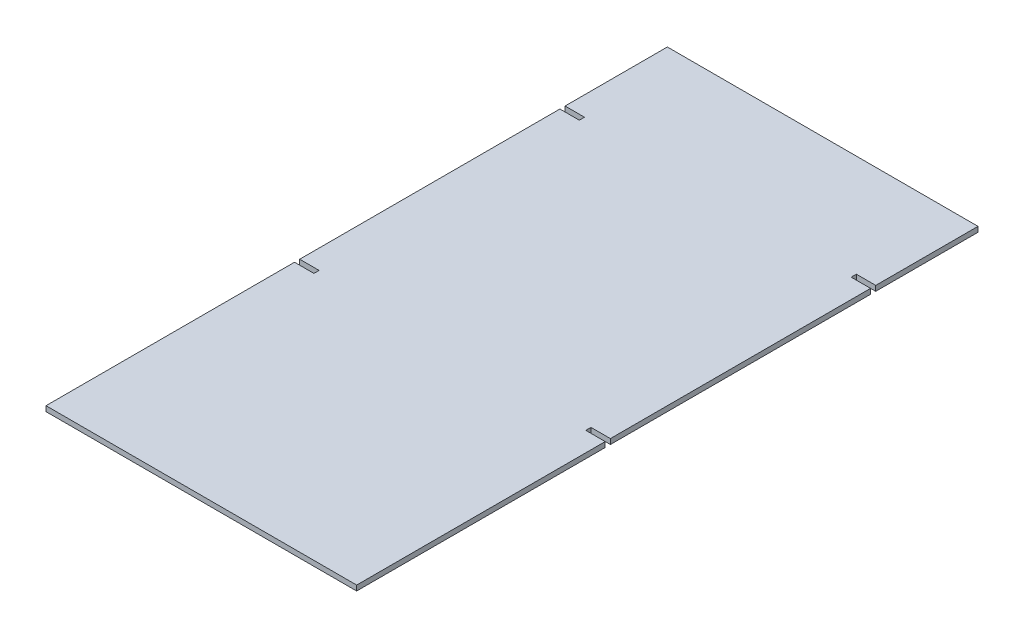
from build123d import *

# Parameters (mm, degrees)
SKETCH1_W           = 304.8
SKETCH1_H           = 609.6
BOSS_EXTRUDE1_DEPTH = 5.08
SKETCH2_W           = 19.05
SKETCH2_H           = 5.08
CUT_EXTRUDE1_DEPTH  = 6.08


with BuildPart() as part:
    # Sketch1 → Boss-Extrude1 (new body)
    with BuildSketch(Plane(origin=(0, 0, 0), x_dir=(1, 0, 0), z_dir=(0, 1, 0))):
        Rectangle(SKETCH1_W, SKETCH1_H)
    extrude(amount=BOSS_EXTRUDE1_DEPTH)

    # Sketch2 → Cut-Extrude1 (cut, through all)
    with BuildSketch(Plane(origin=(0, 5.08, 0), x_dir=(1, 0, 0), z_dir=(0, 1, 0))):
        with Locations((142.875, -58.42)):
            Rectangle(SKETCH2_W, SKETCH2_H)
        with Locations((142.875, 201.93)):
            Rectangle(SKETCH2_W, SKETCH2_H)
        with Locations((-142.875, 201.93)):
            Rectangle(SKETCH2_W, SKETCH2_H)
        with Locations((-142.875, -58.42)):
            Rectangle(SKETCH2_W, SKETCH2_H)
    extrude(amount=-CUT_EXTRUDE1_DEPTH, mode=Mode.SUBTRACT)


solid = part.part
